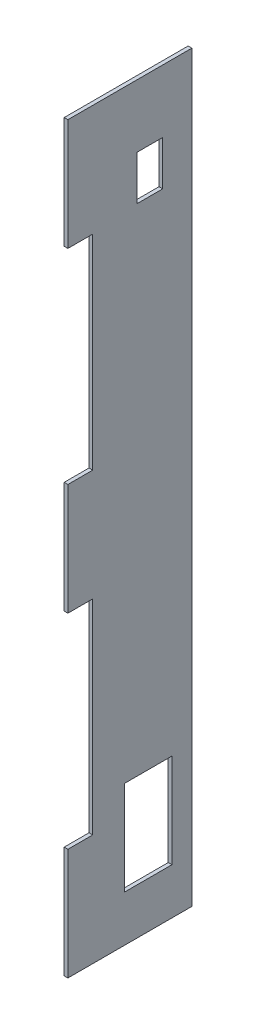
from build123d import *

# Parameters (mm, degrees)
SKETCH1_W           = 1.5
SKETCH1_H           = 50
BOSS_EXTRUDE1_DEPTH = 150
SKETCH2_W           = 10
SKETCH2_H           = 82.5
CUT_EXTRUDE1_DEPTH  = 2.5
SKETCH3_W           = 19.117585256
SKETCH3_H           = 37.973569139
POWERCONN_DEPTH     = 2.5
SKETCH4_W           = 10.297175775
SKETCH4_H           = 17.958343038
USBCONN_DEPTH       = 2.5


with BuildPart() as part:
    # Sketch1 → Boss-Extrude1 (new body, symmetric)
    with BuildSketch(Plane(origin=(0, 0, 0), x_dir=(1, 0, 0), z_dir=(0, 1, 0))):
        Rectangle(SKETCH1_W, SKETCH1_H)
    extrude(amount=BOSS_EXTRUDE1_DEPTH, both=True)

    # Sketch2 → Cut-Extrude1 (cut, through all)
    with BuildSketch(Plane.ZY.offset(0.75)):
        with Locations((20, 63.75)):
            Rectangle(SKETCH2_W, SKETCH2_H)
        with Locations((20, -63.75)):
            Rectangle(SKETCH2_W, SKETCH2_H)
    extrude(amount=-CUT_EXTRUDE1_DEPTH, mode=Mode.SUBTRACT)

    # Sketch3 → PowerConn (cut, through all)
    with BuildSketch(Plane.ZY.offset(0.75)):
        with Locations((-7.430305419, -112.401736371)):
            Rectangle(SKETCH3_W, SKETCH3_H)
    extrude(amount=-POWERCONN_DEPTH, mode=Mode.SUBTRACT)

    # Sketch4 → UsbConn (cut, through all)
    with BuildSketch(Plane.ZY.offset(0.75)):
        with Locations((-8.106092581, 115.676720654)):
            Rectangle(SKETCH4_W, SKETCH4_H)
    extrude(amount=-USBCONN_DEPTH, mode=Mode.SUBTRACT)


solid = part.part
